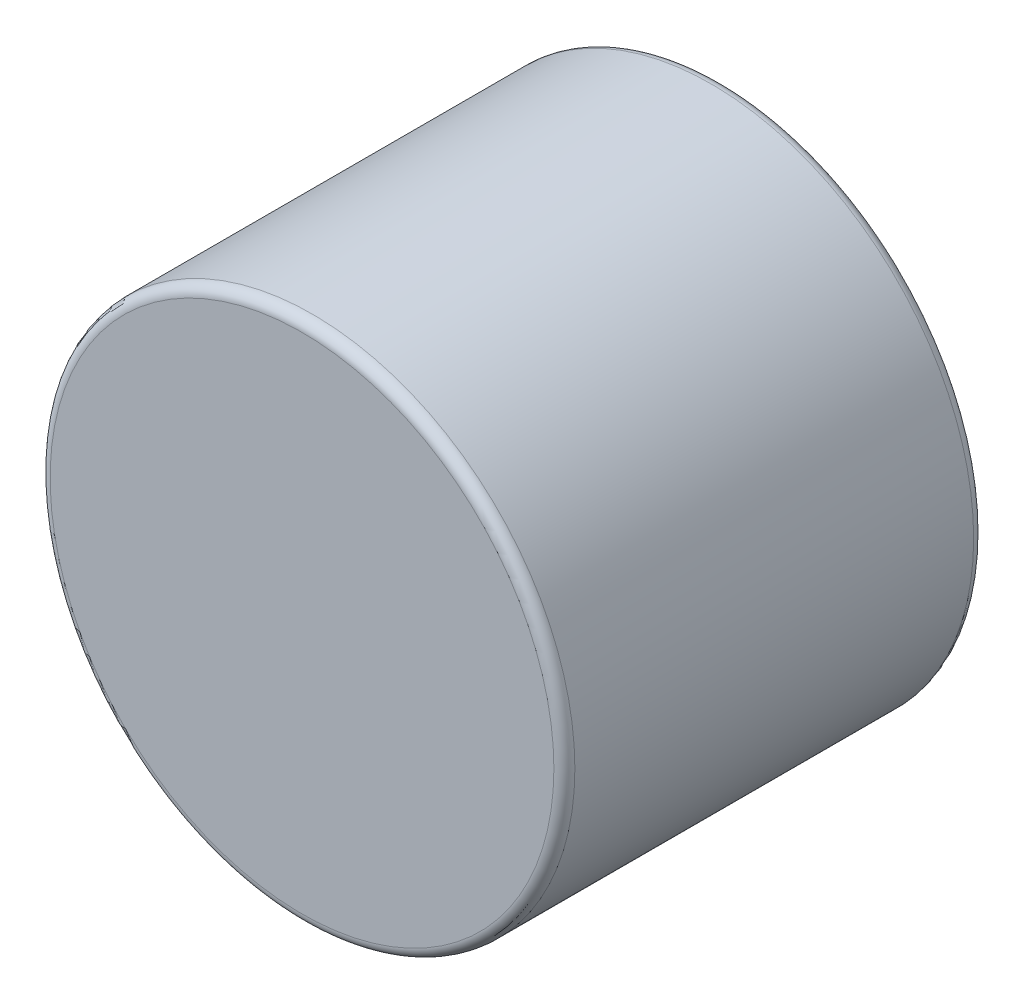
from build123d import *

# Parameters (mm, degrees)
SKETCH3_R                = 3.96875
BOSS_EXTRUDE1_DEPTH      = 3.175
BOSS_EXTRUDE1_DEPTH_BACK = 3.175
FILLET1_R                = 0.15875


with BuildPart() as part:
    # Sketch3 → Boss-Extrude1 (new body, two sides)
    with BuildSketch(Plane.XY) as boss_extrude1_sk:
        Circle(SKETCH3_R)
    extrude(amount=BOSS_EXTRUDE1_DEPTH)
    extrude(boss_extrude1_sk.sketch, amount=-BOSS_EXTRUDE1_DEPTH_BACK)

    # Fillet1
    fillet1_edges = [part.edges().sort_by_distance(p)[0] for p in [
        (-3.96875, 0, -3.175),
        (-3.96875, 0, 3.175),
    ]]
    fillet(fillet1_edges, radius=FILLET1_R)


solid = part.part
